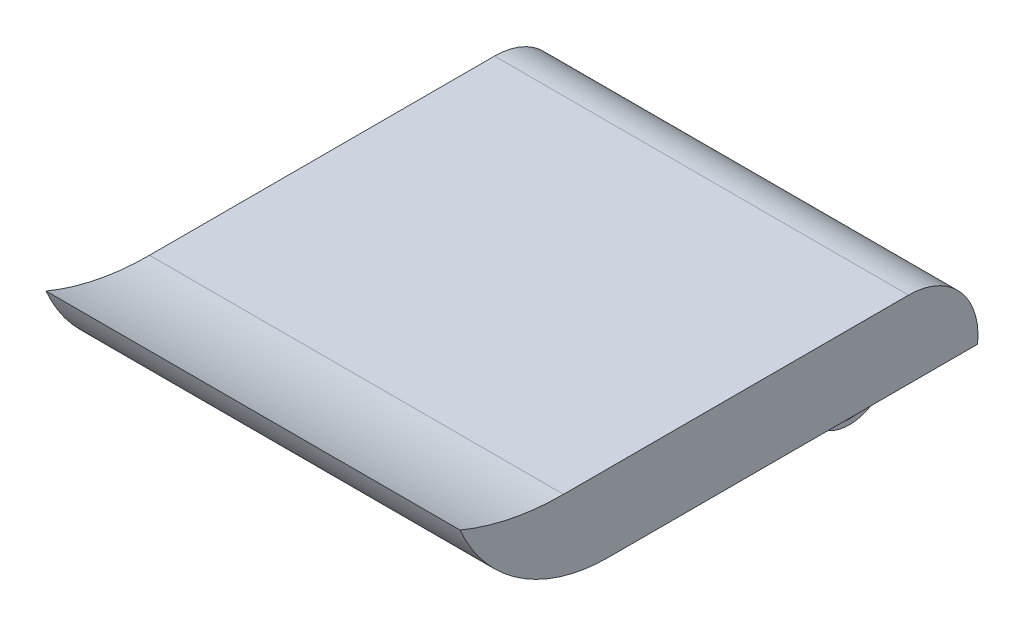
from build123d import *

# Parameters (mm, degrees)
BOSS_EXTRUDE1_DEPTH = 18
SKETCH2_W           = 21
SKETCH2_H           = 7.3
BOSS_EXTRUDE2_DEPTH = 8
CUT_EXTRUDE1_DEPTH  = 29.5
SKETCH4_R           = 2
CUT_EXTRUDE2_DEPTH  = 29.5


with BuildPart() as part:
    # Sketch1 → Boss-Extrude1 (new body, symmetric)
    with BuildSketch(Plane(origin=(0, 0, 0), x_dir=(0, 0, -1), z_dir=(1, 0, 0))):
        with BuildLine():
            Line((-13.605837563, 0), (18.494162437, 0))
            ThreePointArc((18.494162437, 0), (16.991105843, 4.690546334), (12.494162437, 6.7))
            Line((12.494162437, 6.7), (-17.505837563, 6.7))
            ThreePointArc((-17.505837563, 6.7), (-22.095938325, 7.156985164), (-26.505837563, 8.51))
            ThreePointArc((-26.505837563, 8.51), (-21.332902013, 2.319144372), (-13.605837563, 0))
        make_face()
    extrude(amount=BOSS_EXTRUDE1_DEPTH, both=True)

    # Sketch2 → Boss-Extrude2 (add)
    with BuildSketch(Plane.XZ):
        with Locations((0, -14.844162437)):
            Rectangle(SKETCH2_W, SKETCH2_H)
    extrude(amount=BOSS_EXTRUDE2_DEPTH)

    # Sketch3 → Cut-Extrude1 (cut, through all)
    with BuildSketch(Plane.ZY.offset(10.5)):
        with BuildLine():
            Line((-18.494162437, -4.35), (-18.494162437, -8))
            Line((-18.494162437, -8), (-14.844162437, -8))
            ThreePointArc((-14.844162437, -8), (-17.425102188, -6.930939751), (-18.494162437, -4.35))
        make_face()
        with BuildLine():
            ThreePointArc((-11.194162437, -4.35), (-12.263222685, -6.930939751), (-14.844162437, -8))
            Line((-14.844162437, -8), (-11.194162437, -8))
            Line((-11.194162437, -8), (-11.194162437, -4.35))
        make_face()
    extrude(amount=-CUT_EXTRUDE1_DEPTH, mode=Mode.SUBTRACT)

    # Sketch4 → Cut-Extrude2 (cut, through all)
    with BuildSketch(Plane(origin=(10.5, 0, 0), x_dir=(0, 0, -1), z_dir=(1, 0, 0))):
        with Locations((14.844162437, -5.55)):
            Circle(SKETCH4_R)
    extrude(amount=-CUT_EXTRUDE2_DEPTH, mode=Mode.SUBTRACT)


solid = part.part
